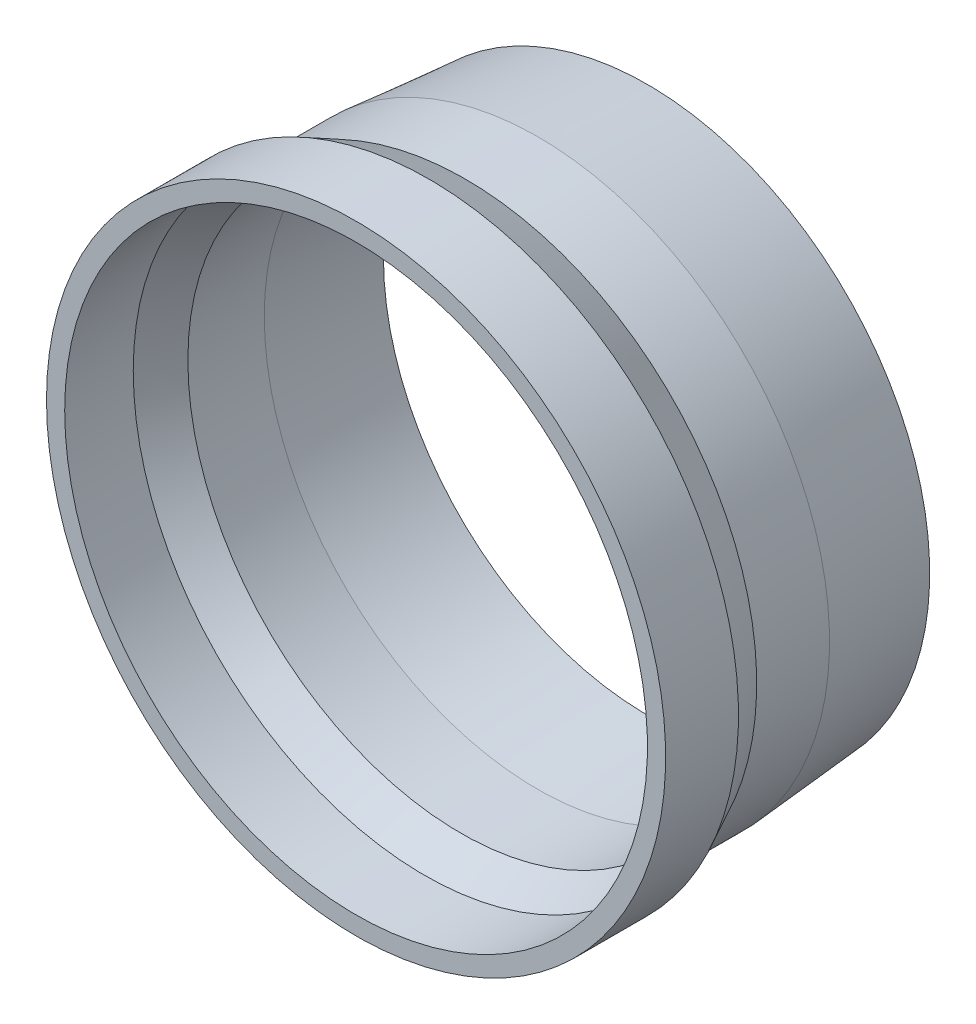
from build123d import *


with BuildPart() as part:
    # Sketch1 → Revolve1 (revolve)
    with BuildSketch(Plane(origin=(0, 0, 0), x_dir=(0, 0, -1), z_dir=(1, 0, 0))):
        Polygon((-38.849515829, 50.8), (-32.499515829, 47.625), (-19.182062788, 47.625), (0, 46.026494768), (0, 49.2125), (-19.05, 50.8), (-31.75, 50.8), (-38.1, 53.975), (-50.8, 53.975), (-50.8, 50.8), align=None)
    revolve(axis=Axis((0, 0, 0), (0, 0, 1)))


solid = part.part
